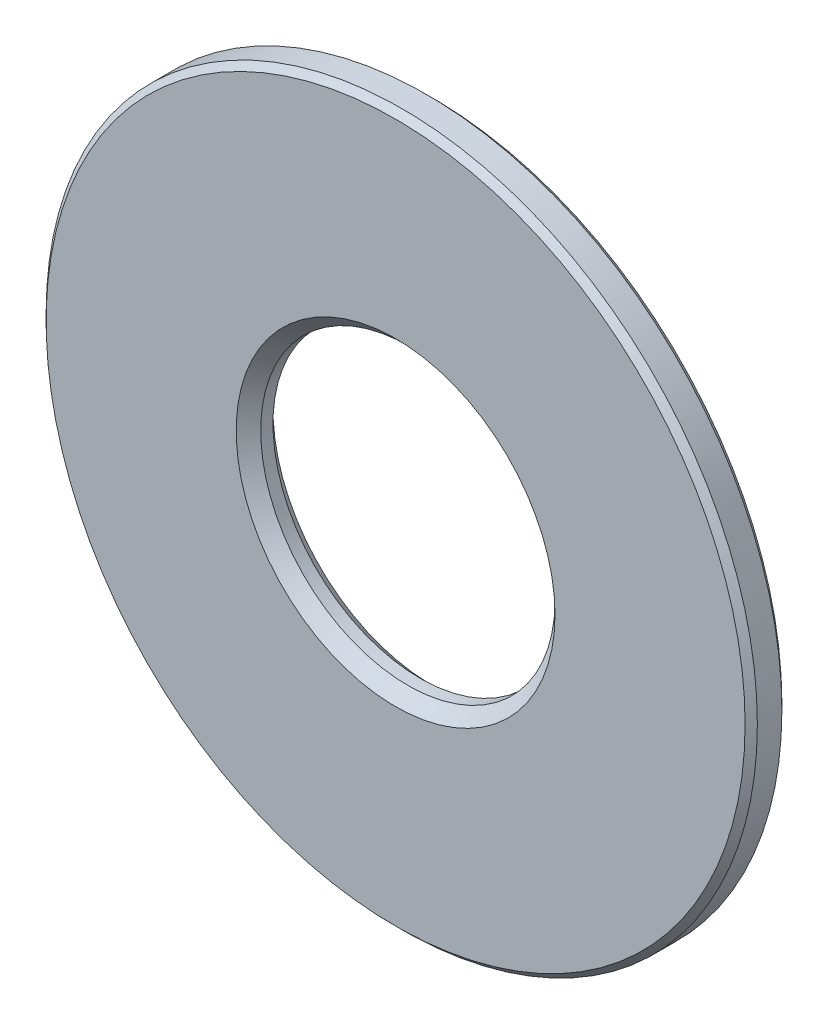
from build123d import *

# Parameters (mm, degrees)
SKETCH1_R           = 29
SKETCH1_R_2         = 12
BOSS_EXTRUDE1_DEPTH = 3
CHAMFER1_SIZE       = 1
CHAMFER2_SIZE       = 0.5


with BuildPart() as part:
    # Sketch1 → Boss-Extrude1 (new body)
    with BuildSketch(Plane.XY):
        Circle(SKETCH1_R)
        Circle(SKETCH1_R_2, mode=Mode.SUBTRACT)
    extrude(amount=BOSS_EXTRUDE1_DEPTH)

    # Chamfer1
    chamfer1_edges = [part.edges().sort_by_distance(p)[0] for p in [
        (-12, 0, 0),
        (-12, 0, 3),
    ]]
    chamfer(chamfer1_edges, length=CHAMFER1_SIZE)

    # Chamfer2
    chamfer2_edges = [part.edges().sort_by_distance(p)[0] for p in [
        (-29, 0, 0),
        (-29, 0, 3),
    ]]
    chamfer(chamfer2_edges, length=CHAMFER2_SIZE)


solid = part.part
